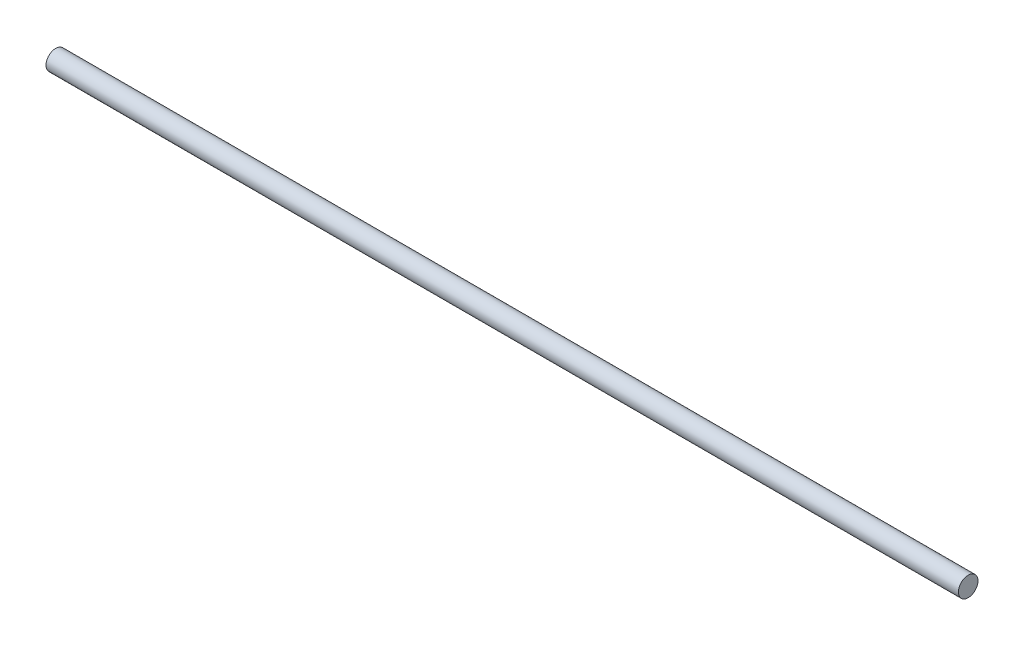
from build123d import *

# Parameters (mm, degrees)
SKETCH1_R           = 3.81
BOSS_EXTRUDE1_DEPTH = 355.6


with BuildPart() as part:
    # Sketch1 → Boss-Extrude1 (new body)
    with BuildSketch(Plane(origin=(0, 0, 0), x_dir=(0, 0, -1), z_dir=(1, 0, 0))):
        Circle(SKETCH1_R)
    extrude(amount=BOSS_EXTRUDE1_DEPTH)


solid = part.part
